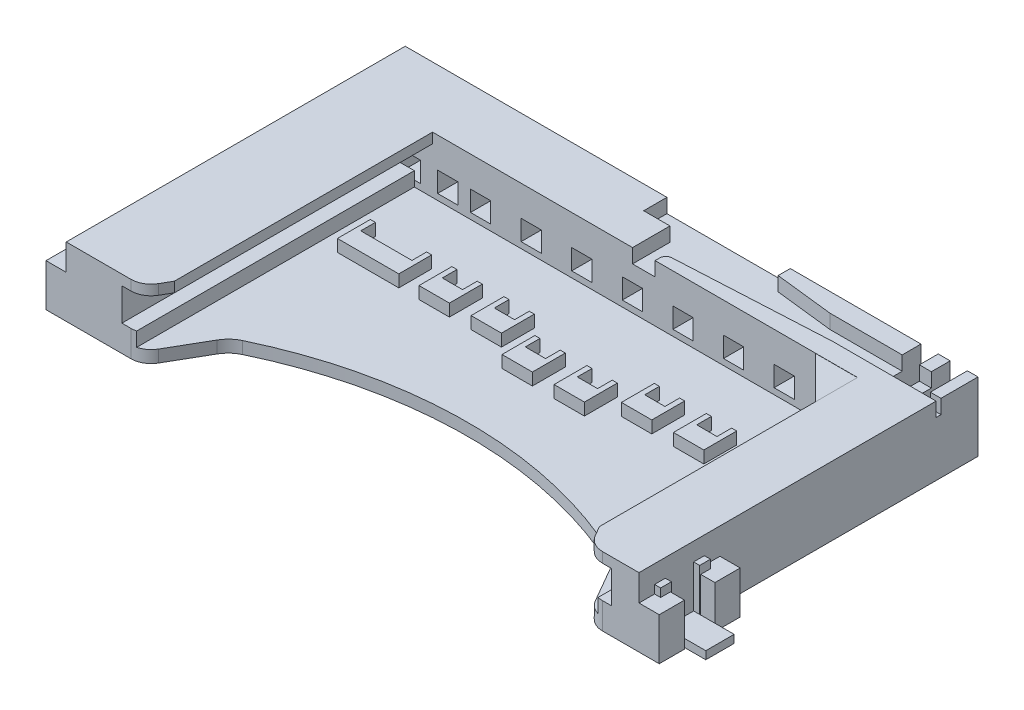
from build123d import *

# Parameters (mm, degrees)
RESSALTO_EXTRUS_O1_DEPTH    = 3.4
CORTE_EXTRUS_O1_DEPTH       = 13.75
CORTE_EXTRUS_O2_DEPTH       = 1
ESBO_O4_W                   = 1.25
ESBO_O4_H                   = 2.1
RESSALTO_EXTRUS_O2_DEPTH    = 1
ESBO_O5_W                   = 0.53
ESBO_O5_H                   = 2.51
RESSALTO_EXTRUS_O3_DEPTH    = 0.3
ESBO_O6_W                   = 1.4
ESBO_O6_H                   = 0.39
RESSALTO_EXTRUS_O4_DEPTH    = 2
ESBO_O7_R                   = 0.75
RESSALTO_EXTRUS_O5_DEPTH    = 0.8
FILETE1_R                   = 0.3
RESSALTO_EXTRUS_O6_DEPTH    = 0.6
RESSALTO_EXTRUS_O7_DEPTH    = 0.6
PADR_O_LINEAR1_COUNT        = 2
PADR_O_LINEAR1_PITCH        = 2.571
PADR_O_LINEAR2_COUNT        = 2
PADR_O_LINEAR2_PITCH        = 10
PADR_O_LINEAR2_COPY_1_DEPTH = 0.6
PADR_O_LINEAR3_COUNT        = 2
PADR_O_LINEAR3_PITCH        = 5
PADR_O_LINEAR3_COUNT_DIR2   = 2
PADR_O_LINEAR3_PITCH_DIR2   = 0.9
PADR_O_LINEAR3_COPY_1_DEPTH = 0.6
PADR_O_LINEAR4_COUNT        = 2
PADR_O_LINEAR4_PITCH        = 15
PADR_O_LINEAR4_COUNT_DIR2   = 2
PADR_O_LINEAR4_PITCH_DIR2   = 2.8
ESBO_O10_W                  = 2.08
ESBO_O10_H                  = 2.08
CORTE_EXTRUS_O3_DEPTH       = 0.01
CORTE_EXTRUS_O4_DEPTH       = 0.7
ESBO_O12_W                  = 0.85
ESBO_O12_H                  = 3.010299587
ESBO_O12_H_2                = 3.148237164
CORTE_EXTRUS_O5_DEPTH       = 2.5
ESBO_O14_W                  = 1
ESBO_O14_H                  = 1
CORTE_EXTRUS_O6_DEPTH       = 3
PADR_O_LINEAR5_COUNT        = 8
PADR_O_LINEAR5_PITCH        = 2.5
PADR_O_LINEAR6_COUNT        = 2
PADR_O_LINEAR6_PITCH        = 1.625
PADR_O_LINEAR7_COUNT        = 2
PADR_O_LINEAR7_PITCH        = 3.47
PADR_O_LINEAR8_COUNT        = 2
PADR_O_LINEAR8_PITCH        = 5.12
ESBO_O15_W                  = 0.5254
ESBO_O15_H                  = 0.24
CORTE_EXTRUS_O7_DEPTH       = 0.7


with BuildPart() as part:
    # Esboço1 → Ressalto-extrusão1 (new body)
    with BuildSketch(Plane(origin=(0, 0, 0), x_dir=(1, 0, 0), z_dir=(0, 1, 0))):
        with BuildLine():
            Line((-10.7865, 26.278571699), (-9.7275, 28.112571699))
            ThreePointArc((-9.7275, 28.112571699), (-9.447610346, 28.46331272), (-9.0765, 28.715571699))
            ThreePointArc((-9.0765, 28.715571699), (0, 30.778382157), (9.0765, 28.715571699))
            ThreePointArc((9.0765, 28.715571699), (9.447610346, 28.46331272), (9.7275, 28.112571699))
            Line((9.7275, 28.112571699), (10.7865, 26.278571699))
            ThreePointArc((10.7865, 26.278571699), (11.152514404, 25.912552647), (11.6525, 25.778571699))
            Line((11.6525, 25.778571699), (13.45, 25.778571699))
            Line((13.45, 25.778571699), (13.45, 42.528571699))
            Line((13.45, 42.528571699), (-14.85, 42.528571699))
            Line((-14.85, 42.528571699), (-14.85, 25.778571699))
            Line((-14.85, 25.778571699), (-11.6525, 25.778571699))
            ThreePointArc((-11.6525, 25.778571699), (-11.152514404, 25.912552647), (-10.7865, 26.278571699))
        make_face()
    extrude(amount=RESSALTO_EXTRUS_O1_DEPTH)

    # Esboço2 → Corte-extrusão1 (cut)
    with BuildSketch(Plane.XY.offset(-25.778571699)):
        Polygon((-11.4, 0.6), (11.4, 0.6), (11.4, 1.3), (12.1, 1.3), (12.1, 2.9), (-12.1, 2.9), (-12.1, 1.3), (-11.4, 1.3), align=None)
    extrude(amount=-CORTE_EXTRUS_O1_DEPTH, mode=Mode.SUBTRACT)

    # Esboço3 → Corte-extrusão2 (cut)
    with BuildSketch(Plane(origin=(0, 3.4, 0), x_dir=(1, 0, 0), z_dir=(0, 1, 0))):
        Polygon((-10.5, 25.778571699), (10.5, 25.778571699), (10.5, 37.448571699), (8.42, 39.528571699), (-10.5, 39.528571699), align=None)
    extrude(amount=-CORTE_EXTRUS_O2_DEPTH, mode=Mode.SUBTRACT)

    # Esboço4 → Ressalto-extrusão2 (add)
    with BuildSketch(Plane(origin=(13.45, 0, 0), x_dir=(0, 0, -1), z_dir=(1, 0, 0))):
        with Locations((26.403571699, 1.05)):
            Rectangle(ESBO_O4_W, ESBO_O4_H)
        with Locations((29.153571699, 1.05)):
            Rectangle(ESBO_O4_W, ESBO_O4_H)
    ressalto_extrus_o2 = extrude(amount=RESSALTO_EXTRUS_O2_DEPTH)

    # Esboço5 → Ressalto-extrusão3 (add)
    with BuildSketch(Plane(origin=(13.45, 0, 0), x_dir=(0, 0, -1), z_dir=(1, 0, 0))):
        with Locations((26.813571699, 1.255)):
            Rectangle(ESBO_O5_W, ESBO_O5_H)
        with Locations((28.743571699, 1.255)):
            Rectangle(ESBO_O5_W, ESBO_O5_H)
    ressalto_extrus_o3 = extrude(amount=RESSALTO_EXTRUS_O3_DEPTH)

    # Esboço6 → Ressalto-extrusão4 (add)
    with BuildSketch(Plane(origin=(13.45, 0, 0), x_dir=(0, 0, -1), z_dir=(1, 0, 0))):
        with Locations((27.778571699, 0.215)):
            Rectangle(ESBO_O6_W, ESBO_O6_H)
    ressalto_extrus_o4 = extrude(amount=RESSALTO_EXTRUS_O4_DEPTH)

    # Espelhar1: Ressalto-extrusão2 across plane
    add(ressalto_extrus_o2.mirror(Plane.ZY.offset(0.7)))

    # Espelhar2: Ressalto-extrusão3, Ressalto-extrusão4 across plane
    add(ressalto_extrus_o3.mirror(Plane.ZY.offset(0.7)))
    add(ressalto_extrus_o4.mirror(Plane.ZY.offset(0.7)))

    # Esboço7 → Ressalto-extrusão5 (add)
    with BuildSketch(Plane(origin=(0, 0, 0), x_dir=(-1, 0, 0), z_dir=(0, -1, 0))):
        with Locations((-11.95, 41.028571699)):
            Circle(ESBO_O7_R)
        with Locations((13.35, 41.028571699)):
            Circle(ESBO_O7_R)
    extrude(amount=RESSALTO_EXTRUS_O5_DEPTH)

    # Filete1
    filete1_edges = [part.edges().sort_by_distance(p)[0] for p in [
        (12.7, -0.8, -41.028571699),
        (-12.6, -0.8, -41.028571699),
    ]]
    fillet(filete1_edges, radius=FILETE1_R)

    # Esboço8 → Ressalto-extrusão6 (add)
    with BuildSketch(Plane(origin=(0, 0.6, 0), x_dir=(1, 0, 0), z_dir=(0, 1, 0))):
        Polygon((-10.5, 36.453571699), (-10.25, 36.453571699), (-10.25, 35.728571699), (-7.718552213, 35.728571699), (-7.718552213, 36.453571699), (-7.468552213, 36.453571699), (-7.468552213, 34.828571699), (-10.5, 34.828571699), align=None)
    extrude(amount=RESSALTO_EXTRUS_O6_DEPTH)

    # Esboço9 → Ressalto-extrusão7 (add)
    with BuildSketch(Plane(origin=(0, 0.6, 0), x_dir=(1, 0, 0), z_dir=(0, 1, 0))):
        Polygon((-6.468552213, 34.828571699), (-4.968552213, 34.828571699), (-4.968552213, 36.453571699), (-5.218552213, 36.453571699), (-5.218552213, 35.728571699), (-6.218552213, 35.728571699), (-6.218552213, 36.453571699), (-6.468552213, 36.453571699), align=None)
    ressalto_extrus_o7 = extrude(amount=RESSALTO_EXTRUS_O7_DEPTH)

    # Padrão linear1: Ressalto-extrusão7 ×2
    with Locations(*[(i * PADR_O_LINEAR1_PITCH, 0, 0) for i in range(1, PADR_O_LINEAR1_COUNT)]):
        add(ressalto_extrus_o7)

    # Padrão linear2: Ressalto-extrusão7 ×2
    with Locations(*[(i * PADR_O_LINEAR2_PITCH, 0, 0) for i in range(1, PADR_O_LINEAR2_COUNT)]):
        add(ressalto_extrus_o7)

    # Padrão linear2 copy 1 sketch → Padrão linear2 copy 1 (add)
    with BuildSketch(Plane(origin=(12.571, 0.6, 0), x_dir=(1, 0, 0), z_dir=(0, 1, 0))):
        Polygon((-6.468552213, 34.828571699), (-4.968552213, 34.828571699), (-4.968552213, 36.453571699), (-5.218552213, 36.453571699), (-5.218552213, 35.728571699), (-6.218552213, 35.728571699), (-6.218552213, 36.453571699), (-6.468552213, 36.453571699), align=None)
    extrude(amount=PADR_O_LINEAR2_COPY_1_DEPTH)

    # Padrão linear3: Ressalto-extrus_o7 2 × 2, 2 skipped
    with Locations(*[(i * PADR_O_LINEAR3_PITCH, 0, j * PADR_O_LINEAR3_PITCH_DIR2) for i in range(PADR_O_LINEAR3_COUNT) for j in range(PADR_O_LINEAR3_COUNT_DIR2) if (i, j) not in ((0, 0), (0, 1), (1, 0))]):
        add(ressalto_extrus_o7)

    # Padrão linear3 copy 1 sketch → Padrão linear3 copy 1 (add)
    with BuildSketch(Plane(origin=(7.571, 0.6, 0.9), x_dir=(1, 0, 0), z_dir=(0, 1, 0))):
        Polygon((-6.468552213, 34.828571699), (-4.968552213, 34.828571699), (-4.968552213, 36.453571699), (-5.218552213, 36.453571699), (-5.218552213, 35.728571699), (-6.218552213, 35.728571699), (-6.218552213, 36.453571699), (-6.468552213, 36.453571699), align=None)
    extrude(amount=PADR_O_LINEAR3_COPY_1_DEPTH)

    # Padrão linear4: Ressalto-extrus_o7 2 × 2, 2 skipped
    with Locations(*[(i * PADR_O_LINEAR4_PITCH, 0, j * PADR_O_LINEAR4_PITCH_DIR2) for i in range(PADR_O_LINEAR4_COUNT) for j in range(PADR_O_LINEAR4_COUNT_DIR2) if (i, j) not in ((0, 0), (0, 1), (1, 0))]):
        add(ressalto_extrus_o7)

    # Esboço10 → Corte-extrusão3 (cut)
    with BuildSketch(Plane(origin=(0, 3.4, 0), x_dir=(1, 0, 0), z_dir=(0, 1, 0))):
        with Locations((9.46, 38.488571699)):
            Rectangle(ESBO_O10_W, ESBO_O10_H)
    extrude(amount=-CORTE_EXTRUS_O3_DEPTH, mode=Mode.SUBTRACT)

    # Esboço11 → Corte-extrusão4 (cut)
    with BuildSketch(Plane(origin=(0, 3.4, 0), x_dir=(1, 0, 0), z_dir=(0, 1, 0))):
        with BuildLine():
            Line((-1.92, 42.528571699), (-1.92, 41.378571699))
            Line((-1.92, 41.378571699), (-0.62, 41.378571699))
            Line((-0.62, 41.378571699), (-0.62, 38.891203839))
            Line((-0.62, 38.891203839), (0.495, 38.891203839))
            Line((0.495, 38.891203839), (0.495, 39.762171699))
            ThreePointArc((0.495, 39.762171699), (0.577387407, 39.968677775), (0.779298396, 40.061760517))
            Line((0.779298396, 40.061760517), (8.350298396, 40.458560517))
            Line((8.350298396, 40.458560517), (12.9246, 40.458560517))
            Line((12.9246, 40.458560517), (12.9246, 41.598571699))
            Line((12.9246, 41.598571699), (7.071, 41.598571699))
            Line((7.071, 41.598571699), (4.175, 41.928571699))
            Line((4.175, 41.928571699), (4.175, 43.072994051))
            Line((4.175, 43.072994051), (-1.92, 42.528571699))
        make_face()
    extrude(amount=-CORTE_EXTRUS_O4_DEPTH, mode=Mode.SUBTRACT)

    # Esboço12 → Corte-extrusão5 (cut)
    with BuildSketch(Plane(origin=(0, 3.4, 0), x_dir=(1, 0, 0), z_dir=(0, 1, 0))):
        with Locations((12.4996, 41.963710311)):
            Rectangle(ESBO_O12_W, ESBO_O12_H)
        with Locations((11.0596, 42.032679099)):
            Rectangle(ESBO_O12_W, ESBO_O12_H_2)
    extrude(amount=-CORTE_EXTRUS_O5_DEPTH, mode=Mode.SUBTRACT)

    # Esboço14 → Corte-extrusão6 (cut)
    with BuildSketch(Plane(origin=(0, 0, -42.528571699), x_dir=(-1, 0, 0), z_dir=(0, 0, -1))):
        with Locations((8.125, 1.4)):
            Rectangle(ESBO_O14_W, ESBO_O14_H)
    corte_extrus_o6 = extrude(amount=-CORTE_EXTRUS_O6_DEPTH, mode=Mode.SUBTRACT)

    # Padrão linear5: Corte-extrusão6 ×8
    with Locations(*[(i * PADR_O_LINEAR5_PITCH, 0, 0) for i in range(1, PADR_O_LINEAR5_COUNT)]):
        add(corte_extrus_o6, mode=Mode.SUBTRACT)

    # Padrão linear6: Corte-extrusão6 ×2
    with Locations(*[(-i * PADR_O_LINEAR6_PITCH, 0, 0) for i in range(1, PADR_O_LINEAR6_COUNT)]):
        add(corte_extrus_o6, mode=Mode.SUBTRACT)

    # Padrão linear7: Corte-extrusão6 ×2
    with Locations(*[(-i * PADR_O_LINEAR7_PITCH, 0, 0) for i in range(1, PADR_O_LINEAR7_COUNT)]):
        add(corte_extrus_o6, mode=Mode.SUBTRACT)

    # Padrão linear8: Corte-extrusão6 ×2
    with Locations(*[(-i * PADR_O_LINEAR8_PITCH, 0, 0) for i in range(1, PADR_O_LINEAR8_COUNT)]):
        add(corte_extrus_o6, mode=Mode.SUBTRACT)

    # Esboço15 → Corte-extrusão7 (cut)
    with BuildSketch(Plane(origin=(0, 3.4, 0), x_dir=(1, 0, 0), z_dir=(0, 1, 0))):
        with Locations((13.1873, 40.578560517)):
            Rectangle(ESBO_O15_W, ESBO_O15_H)
    extrude(amount=-CORTE_EXTRUS_O7_DEPTH, mode=Mode.SUBTRACT)


solid = part.part
